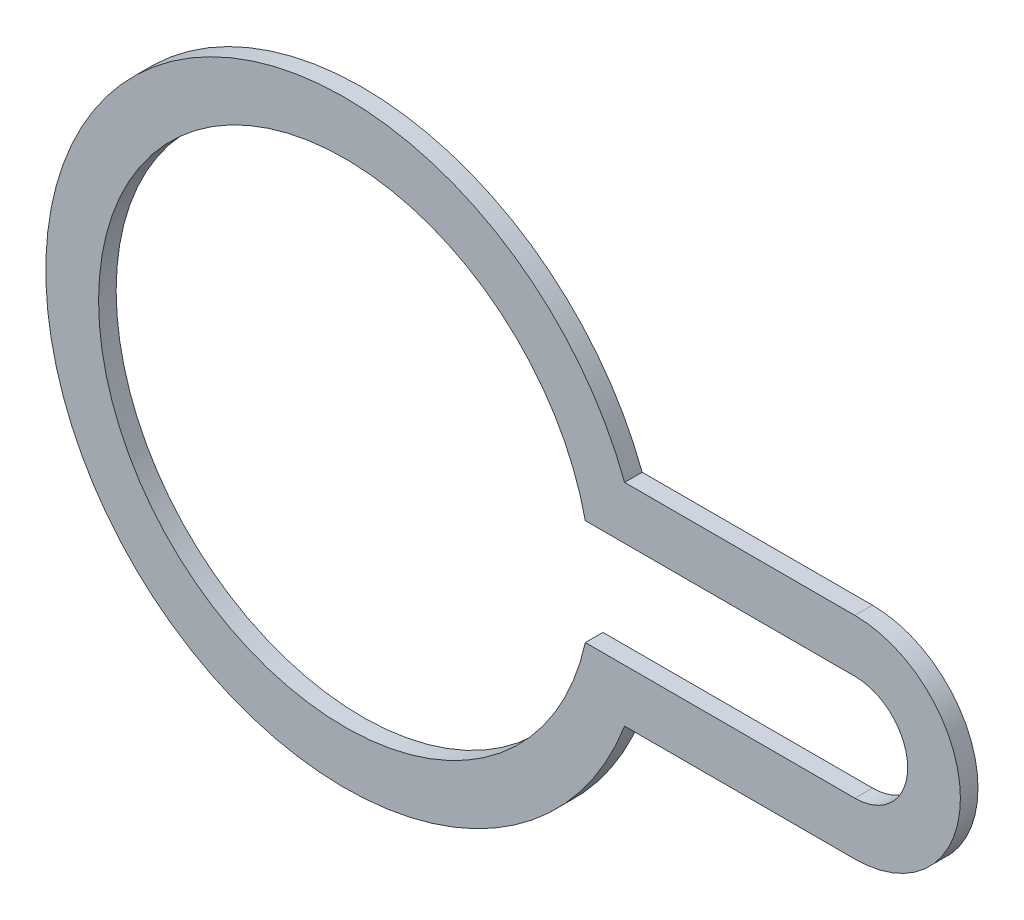
from build123d import *

# Parameters (mm, degrees)
BOSS_EXTRUDE1_DEPTH = 1


with BuildPart() as part:
    # Sketch1 → Boss-Extrude1 (new body)
    with BuildSketch(Plane.XY):
        with BuildLine():
            Line((29, 6), (15.905973721, 6))
            ThreePointArc((15.905973721, 6), (-17, 0), (15.905973721, -6))
            Line((15.905973721, -6), (29, -6))
            ThreePointArc((29, -6), (35, 0), (29, 6))
        make_face()
        with BuildLine():
            Line((13.674794331, 3), (29, 3))
            ThreePointArc((29, 3), (32, 0), (29, -3))
            Line((29, -3), (13.674794331, -3))
            ThreePointArc((13.674794331, -3), (-14, 0), (13.674794331, 3))
        make_face(mode=Mode.SUBTRACT)
    extrude(amount=BOSS_EXTRUDE1_DEPTH)


solid = part.part
